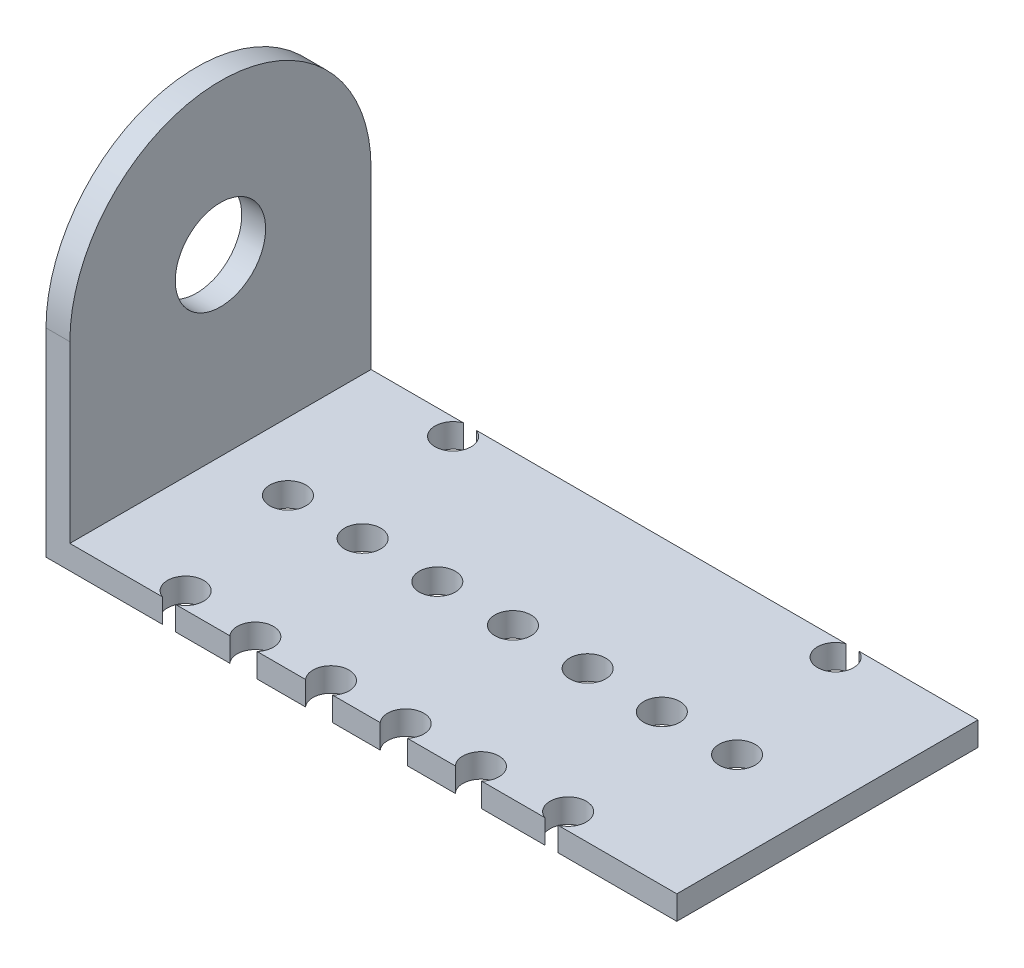
from build123d import *

# Parameters (mm, degrees)
SKETCH1_R           = 1.5
BOSS_EXTRUDE1_DEPTH = 1.98
SKETCH2_W           = 1.98
SKETCH2_H           = 25
BOSS_EXTRUDE2_DEPTH = 14.5
SKETCH3_R           = 12.5
BOSS_EXTRUDE5_DEPTH = 1.98
SKETCH4_R           = 3.75
CUT_EXTRUDE1_DEPTH  = 14.5


with BuildPart() as part:
    # Sketch1 → Boss-Extrude1 (new body)
    with BuildSketch(Plane(origin=(0, 0, 0), x_dir=(1, 0, 0), z_dir=(0, 1, 0))):
        with BuildLine():
            Line((16.298685972, -12.5), (26.18, -12.5))
            Line((26.18, -12.5), (26.18, 12.5))
            Line((26.18, 12.5), (16.298685972, 12.5))
            ThreePointArc((16.298685972, 12.5), (15.760169492, 9.6), (15.221653011, 12.5))
            Line((15.221653011, 12.5), (-15.451314028, 12.5))
            ThreePointArc((-15.451314028, 12.5), (-15.989830508, 9.6), (-16.528346989, 12.5))
            Line((-16.528346989, 12.5), (-26.18, 12.5))
            Line((-26.18, 12.5), (-26.18, -12.5))
            Line((-26.18, -12.5), (-16.528346989, -12.5))
            ThreePointArc((-16.528346989, -12.5), (-16.839014022, -9.863518152), (-14.489830508, -11.1))
            ThreePointArc((-14.489830508, -11.1), (-14.75334866, -11.949183513), (-15.451314028, -12.5))
            Line((-15.451314028, -12.5), (-10.920895266, -12.5))
            ThreePointArc((-10.920895266, -12.5), (-10.315854683, -10.110021252), (-8.289830508, -11.514762712))
            ThreePointArc((-8.289830508, -11.514762712), (-8.385089049, -12.040786886), (-8.658765751, -12.5))
            Line((-8.658765751, -12.5), (-4.640895266, -12.5))
            ThreePointArc((-4.640895266, -12.5), (-4.035854683, -10.110021252), (-2.009830508, -11.514762712))
            ThreePointArc((-2.009830508, -11.514762712), (-2.105089049, -12.040786886), (-2.378765751, -12.5))
            Line((-2.378765751, -12.5), (1.559104734, -12.5))
            ThreePointArc((1.559104734, -12.5), (2.164145317, -10.110021252), (4.190169492, -11.514762712))
            ThreePointArc((4.190169492, -11.514762712), (4.094910951, -12.040786886), (3.821234249, -12.5))
            Line((3.821234249, -12.5), (7.799342787, -12.5))
            ThreePointArc((7.799342787, -12.5), (8.336202009, -10.076431428), (10.390169492, -11.470389831))
            ThreePointArc((10.390169492, -11.470389831), (10.284127894, -12.024357313), (9.980996196, -12.5))
            Line((9.980996196, -12.5), (15.221653011, -12.5))
            ThreePointArc((15.221653011, -12.5), (14.910985978, -9.863518152), (17.260169492, -11.1))
            ThreePointArc((17.260169492, -11.1), (16.99665134, -11.949183513), (16.298685972, -12.5))
        make_face()
        with Locations((-18.6, 0)):
            Circle(SKETCH1_R, mode=Mode.SUBTRACT)
        with Locations((-12.4, 0)):
            Circle(SKETCH1_R, mode=Mode.SUBTRACT)
        with Locations((-6.2, 0)):
            Circle(SKETCH1_R, mode=Mode.SUBTRACT)
        with Locations((0.08, 0)):
            Circle(SKETCH1_R, mode=Mode.SUBTRACT)
        with Locations((6.28, 0)):
            Circle(SKETCH1_R, mode=Mode.SUBTRACT)
        with Locations((12.48, -0.044372881)):
            Circle(SKETCH1_R, mode=Mode.SUBTRACT)
        with Locations((18.68, 0)):
            Circle(SKETCH1_R, mode=Mode.SUBTRACT)
    extrude(amount=BOSS_EXTRUDE1_DEPTH)

    # Sketch2 → Boss-Extrude2 (add)
    with BuildSketch(Plane(origin=(0, 1.98, 0), x_dir=(1, 0, 0), z_dir=(0, 1, 0))):
        with Locations((-25.19, 0)):
            Rectangle(SKETCH2_W, SKETCH2_H)
    extrude(amount=BOSS_EXTRUDE2_DEPTH)

    # Sketch3 → Boss-Extrude5 (add)
    with BuildSketch(Plane.ZY.offset(26.18)):
        with Locations((0, 16.48)):
            Circle(SKETCH3_R)
    extrude(amount=-BOSS_EXTRUDE5_DEPTH)

    # Sketch4 → Cut-Extrude1 (cut)
    with BuildSketch(Plane.ZY.offset(26.18)):
        with Locations((0, 16.48)):
            Circle(SKETCH4_R)
    extrude(amount=-CUT_EXTRUDE1_DEPTH, mode=Mode.SUBTRACT)


solid = part.part
